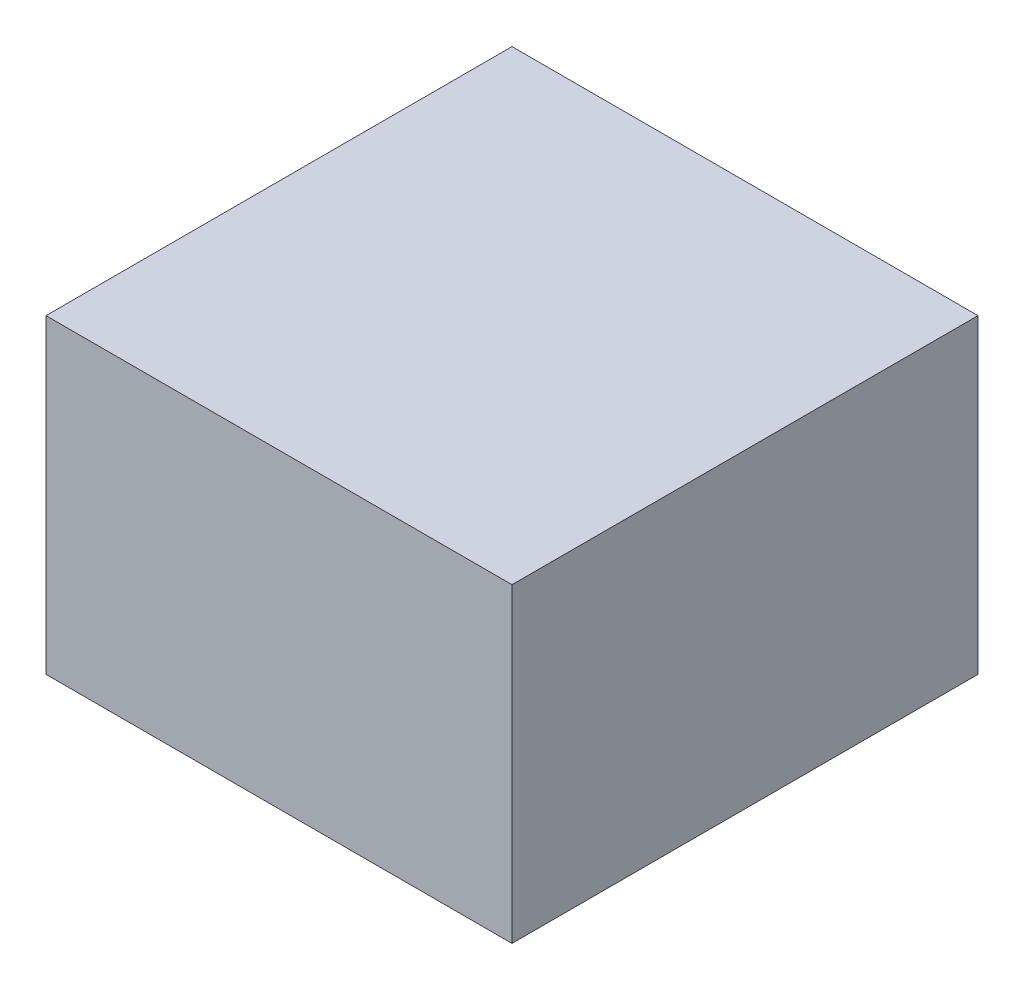
from build123d import *

# Parameters (mm, degrees)
SKETCH1_W           = 60
SKETCH1_H           = 40
BOSS_EXTRUDE1_DEPTH = 60


with BuildPart() as part:
    # Sketch1 → Boss-Extrude1 (new body)
    with BuildSketch(Plane.XY):
        with Locations((-4.60424849, 0)):
            Rectangle(SKETCH1_W, SKETCH1_H)
    extrude(amount=BOSS_EXTRUDE1_DEPTH)


solid = part.part
